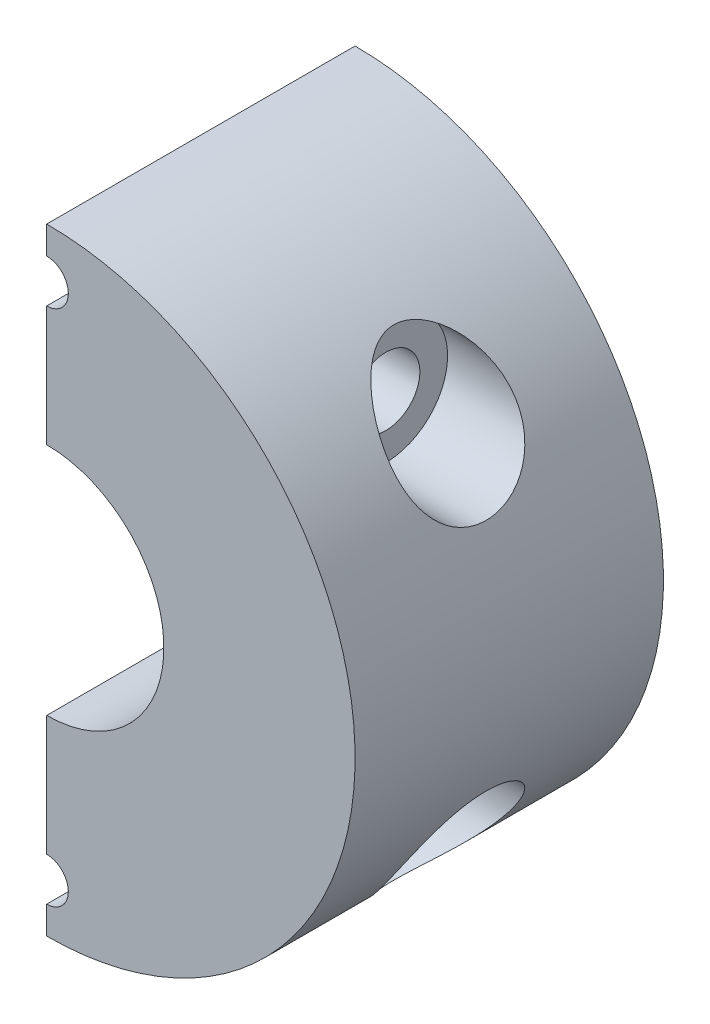
from build123d import *

# Parameters (mm, degrees)
SKETCH1_R           = 25
BOSS_EXTRUDE1_DEPTH = 25
SKETCH2_R           = 9.5
CUT_EXTRUDE1_DEPTH  = 20
SKETCH3_R           = 6
CUT_EXTRUDE2_DEPTH  = 20
SKETCH4_W           = 31.902567833
SKETCH4_H           = 50
CUT_EXTRUDE3_DEPTH  = 26
SKETCH5_R           = 2.75
CUT_EXTRUDE4_DEPTH  = 26
CUT_EXTRUDE5_START  = -15
SKETCH6_R           = 5
CUT_EXTRUDE5_DEPTH  = 20
SKETCH7_R           = 1.75
CUT_EXTRUDE6_DEPTH  = 26.0000001
SKETCH8_R           = 3.5
CUT_EXTRUDE7_DEPTH  = 5


with BuildPart() as part:
    # Sketch1 → Boss-Extrude1 (new body)
    with BuildSketch(Plane.XY):
        Circle(SKETCH1_R)
    extrude(amount=BOSS_EXTRUDE1_DEPTH)

    # Sketch2 → Cut-Extrude1 (cut)
    with BuildSketch(Plane.XY.offset(25)):
        Circle(SKETCH2_R)
    extrude(amount=-CUT_EXTRUDE1_DEPTH, mode=Mode.SUBTRACT)

    # Sketch3 → Cut-Extrude2 (cut)
    with BuildSketch(Plane.XY.offset(5)):
        Circle(SKETCH3_R)
    extrude(amount=-CUT_EXTRUDE2_DEPTH, mode=Mode.SUBTRACT)

    # Sketch4 → Cut-Extrude3 (cut, through all)
    with BuildSketch(Plane.XY.offset(25)):
        with Locations((-15.951283917, 0)):
            Rectangle(SKETCH4_W, SKETCH4_H)
    extrude(amount=-CUT_EXTRUDE3_DEPTH, mode=Mode.SUBTRACT)

    # Sketch5 → Cut-Extrude4 (cut, through all)
    with BuildSketch(Plane.ZY):
        with Locations((12.5, -14.5)):
            Circle(SKETCH5_R)
        with Locations((12.5, 14.5)):
            Circle(SKETCH5_R)
    extrude(amount=-CUT_EXTRUDE4_DEPTH, mode=Mode.SUBTRACT)

    # Sketch6 → Cut-Extrude5 (cut)
    with BuildSketch(Plane.ZY.offset(CUT_EXTRUDE5_START)):
        with Locations((12.5, 14.5)):
            Circle(SKETCH6_R)
        with Locations((12.5, -14.5)):
            Circle(SKETCH6_R)
    extrude(amount=-CUT_EXTRUDE5_DEPTH, mode=Mode.SUBTRACT)

    # Sketch7 → Cut-Extrude6 (cut, through all)
    with BuildSketch(Plane.XY.offset(25)):
        with Locations((0, 21)):
            Circle(SKETCH7_R)
        with Locations((0, -21)):
            Circle(SKETCH7_R)
    extrude(amount=-CUT_EXTRUDE6_DEPTH, mode=Mode.SUBTRACT)

    # Sketch8 → Cut-Extrude7 (cut)
    with BuildSketch(Plane(origin=(0, 0, 0), x_dir=(-1, 0, 0), z_dir=(0, 0, -1))):
        with Locations((0, 21)):
            Circle(SKETCH8_R)
        with Locations((0, -21)):
            Circle(SKETCH8_R)
    extrude(amount=-CUT_EXTRUDE7_DEPTH, mode=Mode.SUBTRACT)


solid = part.part
